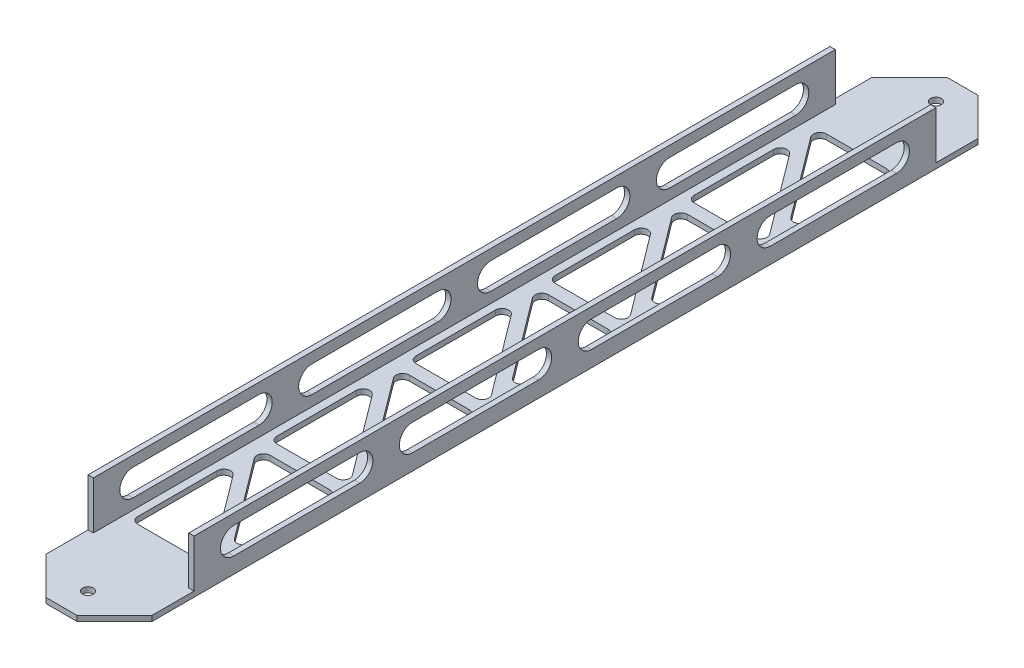
from build123d import *

# Parameters (mm, degrees)
BOSS_EXTRUDE1_DEPTH   = 431.8
SKETCH2_W             = 50.8
SKETCH2_H             = 38.1
TABS_DEPTH            = 22.86
HOLES_REACH           = 4.54
SKETCH3_R             = 2.5796875
SLOTS_DEPTH           = 51.8
TRIG_HOLES_REACH      = 27.4
TAB_CORNER_CUTS_REACH = 27.4


with BuildPart() as part:
    # Sketch1 → Boss-Extrude1 (new body)
    with BuildSketch(Plane.XY):
        Polygon((48.26, 2.54), (48.26, 25.4), (50.8, 25.4), (50.8, 0), (0, 0), (0, 25.4), (2.54, 25.4), (2.54, 2.54), align=None)
    extrude(amount=BOSS_EXTRUDE1_DEPTH)

    # Sketch2 → Tabs (cut)
    with BuildSketch(Plane(origin=(0, 25.4, 0), x_dir=(1, 0, 0), z_dir=(0, 1, 0))):
        with Locations((25.4, -412.75)):
            Rectangle(SKETCH2_W, SKETCH2_H)
        with Locations((25.4, -19.05)):
            Rectangle(SKETCH2_W, SKETCH2_H)
    extrude(amount=-TABS_DEPTH, mode=Mode.SUBTRACT)

    # Sketch3 → Holes (cut, up to next)
    with BuildSketch(Plane(origin=(0, 2.54, 0), x_dir=(1, 0, 0), z_dir=(0, 1, 0)), mode=Mode.PRIVATE) as holes_sk1:
        with Locations((25.4, -419.1)):
            Circle(SKETCH3_R)
    holes_tool1 = extrude(holes_sk1.sketch, amount=-HOLES_REACH, mode=Mode.PRIVATE) & part.part
    add(holes_tool1.solids().sort_by_distance((25.4, 2.54, 419.1))[0], mode=Mode.SUBTRACT)
    # Sketch3 → Holes (cut, up to next)
    with BuildSketch(Plane(origin=(0, 2.54, 0), x_dir=(1, 0, 0), z_dir=(0, 1, 0)), mode=Mode.PRIVATE) as holes_sk2:
        with Locations((25.4, -12.7)):
            Circle(SKETCH3_R)
    holes_tool2 = extrude(holes_sk2.sketch, amount=-HOLES_REACH, mode=Mode.PRIVATE) & part.part
    add(holes_tool2.solids().sort_by_distance((25.4, 2.54, 12.7))[0], mode=Mode.SUBTRACT)

    # Sketch4 → Slots (cut, through all)
    with BuildSketch(Plane(origin=(50.8, 0, 0), x_dir=(0, 0, -1), z_dir=(1, 0, 0))):
        with BuildLine():
            Line((-57.15, 7.62), (-117.475, 7.62))
            ThreePointArc((-117.475, 7.62), (-123.825, 13.97), (-117.475, 20.32))
            Line((-117.475, 20.32), (-57.15, 20.32))
            ThreePointArc((-57.15, 20.32), (-50.8, 13.97), (-57.15, 7.62))
        make_face()
        with BuildLine():
            Line((-142.875, 7.62), (-203.2, 7.62))
            ThreePointArc((-203.2, 7.62), (-209.55, 13.97), (-203.2, 20.32))
            Line((-203.2, 20.32), (-142.875, 20.32))
            ThreePointArc((-142.875, 20.32), (-136.525, 13.97), (-142.875, 7.62))
        make_face()
        with BuildLine():
            Line((-228.6, 7.62), (-288.925, 7.62))
            ThreePointArc((-288.925, 7.62), (-295.275, 13.97), (-288.925, 20.32))
            Line((-288.925, 20.32), (-228.6, 20.32))
            ThreePointArc((-228.6, 20.32), (-222.25, 13.97), (-228.6, 7.62))
        make_face()
        with BuildLine():
            Line((-314.325, 7.62), (-374.65, 7.62))
            ThreePointArc((-374.65, 7.62), (-381, 13.97), (-374.65, 20.32))
            Line((-374.65, 20.32), (-314.325, 20.32))
            ThreePointArc((-314.325, 20.32), (-307.975, 13.97), (-314.325, 7.62))
        make_face()
    extrude(amount=-SLOTS_DEPTH, mode=Mode.SUBTRACT)

    # Sketch5 → Trig_Holes (cut, up to next)
    with BuildSketch(Plane.XZ, mode=Mode.PRIVATE) as trig_holes_sk1:
        with BuildLine():
            Line((41.275, 52.3875), (12.7, 52.3875))
            ThreePointArc((12.7, 52.3875), (9.860193669, 54.142596834), (10.16, 57.4675))
            Line((10.16, 57.4675), (38.735, 95.5675))
            ThreePointArc((38.735, 95.5675), (42.279023157, 96.674569471), (44.45, 93.6625))
            Line((44.45, 93.6625), (44.45, 55.5625))
            ThreePointArc((44.45, 55.5625), (43.52006403, 53.31743597), (41.275, 52.3875))
        make_face()
    trig_holes_tool1 = extrude(trig_holes_sk1.sketch, amount=-TRIG_HOLES_REACH, mode=Mode.PRIVATE) & part.part
    add(trig_holes_tool1.solids().sort_by_distance((31.731608, 0, 68.958649))[0], mode=Mode.SUBTRACT)
    # Sketch5 → Trig_Holes (cut, up to next)
    with BuildSketch(Plane.XZ, mode=Mode.PRIVATE) as trig_holes_sk2:
        with BuildLine():
            Line((9.525, 112.7125), (38.1, 112.7125))
            ThreePointArc((38.1, 112.7125), (40.939806331, 110.957403166), (40.64, 107.6325))
            Line((40.64, 107.6325), (12.065, 69.5325))
            ThreePointArc((12.065, 69.5325), (8.520976843, 68.425430529), (6.35, 71.4375))
            Line((6.35, 71.4375), (6.35, 109.5375))
            ThreePointArc((6.35, 109.5375), (7.27993597, 111.78256403), (9.525, 112.7125))
        make_face()
    trig_holes_tool2 = extrude(trig_holes_sk2.sketch, amount=-TRIG_HOLES_REACH, mode=Mode.PRIVATE) & part.part
    add(trig_holes_tool2.solids().sort_by_distance((19.068392, 0, 96.141351))[0], mode=Mode.SUBTRACT)
    # Sketch5 → Trig_Holes (cut, up to next)
    with BuildSketch(Plane.XZ, mode=Mode.PRIVATE) as trig_holes_sk3:
        with BuildLine():
            Line((41.275, 119.0625), (12.7, 119.0625))
            ThreePointArc((12.7, 119.0625), (9.860193669, 120.817596834), (10.16, 124.1425))
            Line((10.16, 124.1425), (38.735, 162.2425))
            ThreePointArc((38.735, 162.2425), (42.279023157, 163.349569471), (44.45, 160.3375))
            Line((44.45, 160.3375), (44.45, 122.2375))
            ThreePointArc((44.45, 122.2375), (43.52006403, 119.99243597), (41.275, 119.0625))
        make_face()
    trig_holes_tool3 = extrude(trig_holes_sk3.sketch, amount=-TRIG_HOLES_REACH, mode=Mode.PRIVATE) & part.part
    add(trig_holes_tool3.solids().sort_by_distance((31.731608, 0, 135.633649))[0], mode=Mode.SUBTRACT)
    # Sketch5 → Trig_Holes (cut, up to next)
    with BuildSketch(Plane.XZ, mode=Mode.PRIVATE) as trig_holes_sk4:
        with BuildLine():
            Line((9.525, 179.3875), (38.1, 179.3875))
            ThreePointArc((38.1, 179.3875), (40.939806331, 177.632403166), (40.64, 174.3075))
            Line((40.64, 174.3075), (12.065, 136.2075))
            ThreePointArc((12.065, 136.2075), (8.520976843, 135.100430529), (6.35, 138.1125))
            Line((6.35, 138.1125), (6.35, 176.2125))
            ThreePointArc((6.35, 176.2125), (7.27993597, 178.45756403), (9.525, 179.3875))
        make_face()
    trig_holes_tool4 = extrude(trig_holes_sk4.sketch, amount=-TRIG_HOLES_REACH, mode=Mode.PRIVATE) & part.part
    add(trig_holes_tool4.solids().sort_by_distance((19.068392, 0, 162.816351))[0], mode=Mode.SUBTRACT)
    # Sketch5 → Trig_Holes (cut, up to next)
    with BuildSketch(Plane.XZ, mode=Mode.PRIVATE) as trig_holes_sk5:
        with BuildLine():
            Line((41.275, 185.7375), (12.7, 185.7375))
            ThreePointArc((12.7, 185.7375), (9.860193669, 187.492596834), (10.16, 190.8175))
            Line((10.16, 190.8175), (38.735, 228.9175))
            ThreePointArc((38.735, 228.9175), (42.279023157, 230.024569471), (44.45, 227.0125))
            Line((44.45, 227.0125), (44.45, 188.9125))
            ThreePointArc((44.45, 188.9125), (43.52006403, 186.66743597), (41.275, 185.7375))
        make_face()
    trig_holes_tool5 = extrude(trig_holes_sk5.sketch, amount=-TRIG_HOLES_REACH, mode=Mode.PRIVATE) & part.part
    add(trig_holes_tool5.solids().sort_by_distance((31.731608, 0, 202.308649))[0], mode=Mode.SUBTRACT)
    # Sketch5 → Trig_Holes (cut, up to next)
    with BuildSketch(Plane.XZ, mode=Mode.PRIVATE) as trig_holes_sk6:
        with BuildLine():
            Line((9.525, 246.0625), (38.1, 246.0625))
            ThreePointArc((38.1, 246.0625), (40.939806331, 244.307403166), (40.64, 240.9825))
            Line((40.64, 240.9825), (12.065, 202.8825))
            ThreePointArc((12.065, 202.8825), (8.520976843, 201.775430529), (6.35, 204.7875))
            Line((6.35, 204.7875), (6.35, 242.8875))
            ThreePointArc((6.35, 242.8875), (7.27993597, 245.13256403), (9.525, 246.0625))
        make_face()
    trig_holes_tool6 = extrude(trig_holes_sk6.sketch, amount=-TRIG_HOLES_REACH, mode=Mode.PRIVATE) & part.part
    add(trig_holes_tool6.solids().sort_by_distance((19.068392, 0, 229.491351))[0], mode=Mode.SUBTRACT)
    # Sketch5 → Trig_Holes (cut, up to next)
    with BuildSketch(Plane.XZ, mode=Mode.PRIVATE) as trig_holes_sk7:
        with BuildLine():
            Line((41.275, 252.4125), (12.7, 252.4125))
            ThreePointArc((12.7, 252.4125), (9.860193669, 254.167596834), (10.16, 257.4925))
            Line((10.16, 257.4925), (38.735, 295.5925))
            ThreePointArc((38.735, 295.5925), (42.279023157, 296.699569471), (44.45, 293.6875))
            Line((44.45, 293.6875), (44.45, 255.5875))
            ThreePointArc((44.45, 255.5875), (43.52006403, 253.34243597), (41.275, 252.4125))
        make_face()
    trig_holes_tool7 = extrude(trig_holes_sk7.sketch, amount=-TRIG_HOLES_REACH, mode=Mode.PRIVATE) & part.part
    add(trig_holes_tool7.solids().sort_by_distance((31.731608, 0, 268.983649))[0], mode=Mode.SUBTRACT)
    # Sketch5 → Trig_Holes (cut, up to next)
    with BuildSketch(Plane.XZ, mode=Mode.PRIVATE) as trig_holes_sk8:
        with BuildLine():
            Line((9.525, 312.7375), (38.1, 312.7375))
            ThreePointArc((38.1, 312.7375), (40.939806331, 310.982403166), (40.64, 307.6575))
            Line((40.64, 307.6575), (12.065, 269.5575))
            ThreePointArc((12.065, 269.5575), (8.520976843, 268.450430529), (6.35, 271.4625))
            Line((6.35, 271.4625), (6.35, 309.5625))
            ThreePointArc((6.35, 309.5625), (7.27993597, 311.80756403), (9.525, 312.7375))
        make_face()
    trig_holes_tool8 = extrude(trig_holes_sk8.sketch, amount=-TRIG_HOLES_REACH, mode=Mode.PRIVATE) & part.part
    add(trig_holes_tool8.solids().sort_by_distance((19.068392, 0, 296.166351))[0], mode=Mode.SUBTRACT)
    # Sketch5 → Trig_Holes (cut, up to next)
    with BuildSketch(Plane.XZ, mode=Mode.PRIVATE) as trig_holes_sk9:
        with BuildLine():
            Line((41.275, 319.0875), (12.7, 319.0875))
            ThreePointArc((12.7, 319.0875), (9.860193669, 320.842596834), (10.16, 324.1675))
            Line((10.16, 324.1675), (38.735, 362.2675))
            ThreePointArc((38.735, 362.2675), (42.279023157, 363.374569471), (44.45, 360.3625))
            Line((44.45, 360.3625), (44.45, 322.2625))
            ThreePointArc((44.45, 322.2625), (43.52006403, 320.01743597), (41.275, 319.0875))
        make_face()
    trig_holes_tool9 = extrude(trig_holes_sk9.sketch, amount=-TRIG_HOLES_REACH, mode=Mode.PRIVATE) & part.part
    add(trig_holes_tool9.solids().sort_by_distance((31.731608, 0, 335.658649))[0], mode=Mode.SUBTRACT)
    # Sketch5 → Trig_Holes (cut, up to next)
    with BuildSketch(Plane.XZ, mode=Mode.PRIVATE) as trig_holes_sk10:
        with BuildLine():
            Line((9.525, 379.4125), (38.1, 379.4125))
            ThreePointArc((38.1, 379.4125), (40.939806331, 377.657403166), (40.64, 374.3325))
            Line((40.64, 374.3325), (12.065, 336.2325))
            ThreePointArc((12.065, 336.2325), (8.520976843, 335.125430529), (6.35, 338.1375))
            Line((6.35, 338.1375), (6.35, 376.2375))
            ThreePointArc((6.35, 376.2375), (7.27993597, 378.48256403), (9.525, 379.4125))
        make_face()
    trig_holes_tool10 = extrude(trig_holes_sk10.sketch, amount=-TRIG_HOLES_REACH, mode=Mode.PRIVATE) & part.part
    add(trig_holes_tool10.solids().sort_by_distance((19.068392, 0, 362.841351))[0], mode=Mode.SUBTRACT)

    # Sketch6 → Tab_Corner_Cuts (cut, up to next)
    with BuildSketch(Plane.XZ, mode=Mode.PRIVATE) as tab_corner_cuts_sk1:
        Polygon((32.839487758, 0), (50.8, 17.960512242), (50.8, 0), align=None)
    tab_corner_cuts_tool1 = extrude(tab_corner_cuts_sk1.sketch, amount=-TAB_CORNER_CUTS_REACH, mode=Mode.PRIVATE) & part.part
    add(tab_corner_cuts_tool1.solids().sort_by_distance((44.813163, 0, 5.986837))[0], mode=Mode.SUBTRACT)
    # Sketch6 → Tab_Corner_Cuts (cut, up to next)
    with BuildSketch(Plane.XZ, mode=Mode.PRIVATE) as tab_corner_cuts_sk2:
        Polygon((17.960512242, 0), (0, 17.960512242), (0, 0), align=None)
    tab_corner_cuts_tool2 = extrude(tab_corner_cuts_sk2.sketch, amount=-TAB_CORNER_CUTS_REACH, mode=Mode.PRIVATE) & part.part
    add(tab_corner_cuts_tool2.solids().sort_by_distance((5.986837, 0, 5.986837))[0], mode=Mode.SUBTRACT)
    # Sketch6 → Tab_Corner_Cuts (cut, up to next)
    with BuildSketch(Plane.XZ, mode=Mode.PRIVATE) as tab_corner_cuts_sk3:
        Polygon((32.839487758, 431.8), (50.8, 413.839487758), (50.8, 431.8), align=None)
    tab_corner_cuts_tool3 = extrude(tab_corner_cuts_sk3.sketch, amount=-TAB_CORNER_CUTS_REACH, mode=Mode.PRIVATE) & part.part
    add(tab_corner_cuts_tool3.solids().sort_by_distance((44.813163, 0, 425.813163))[0], mode=Mode.SUBTRACT)
    # Sketch6 → Tab_Corner_Cuts (cut, up to next)
    with BuildSketch(Plane.XZ, mode=Mode.PRIVATE) as tab_corner_cuts_sk4:
        Polygon((17.960512242, 431.8), (0, 413.839487758), (0, 431.8), align=None)
    tab_corner_cuts_tool4 = extrude(tab_corner_cuts_sk4.sketch, amount=-TAB_CORNER_CUTS_REACH, mode=Mode.PRIVATE) & part.part
    add(tab_corner_cuts_tool4.solids().sort_by_distance((5.986837, 0, 425.813163))[0], mode=Mode.SUBTRACT)


solid = part.part
